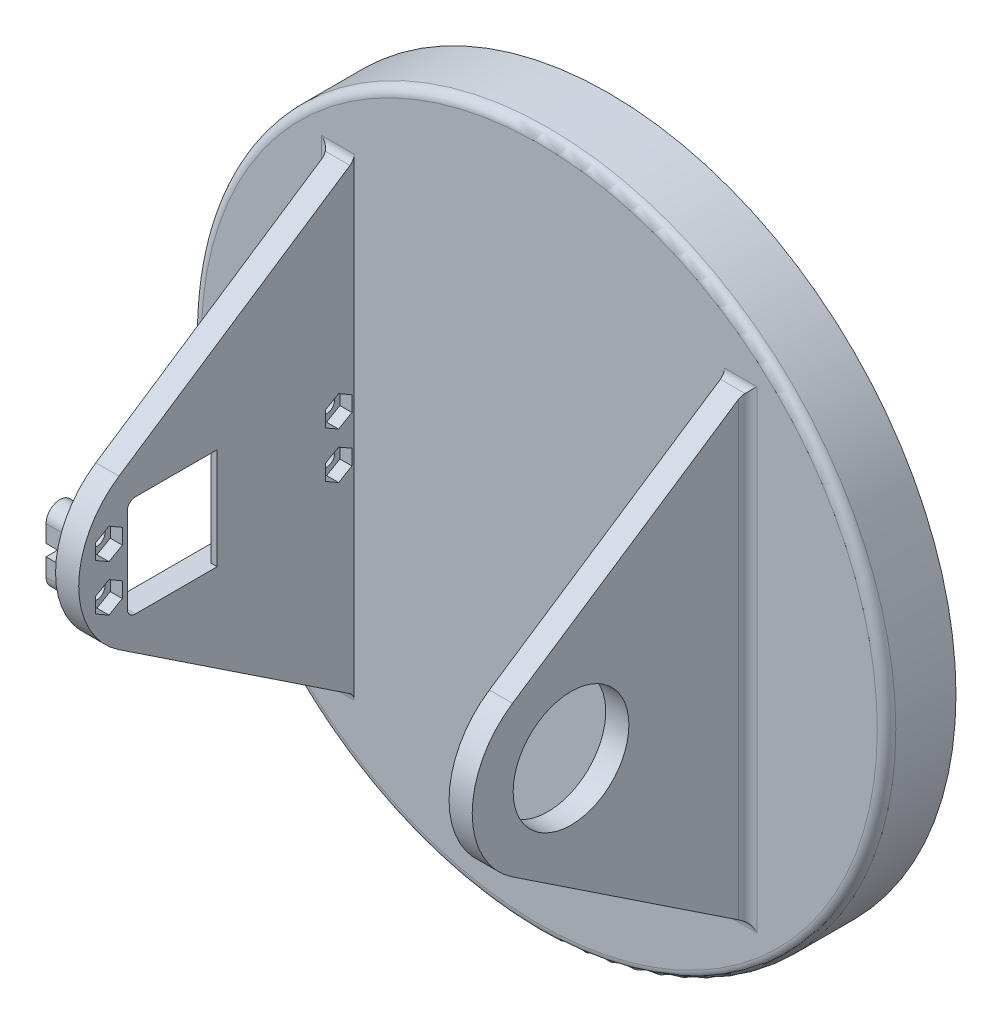
from build123d import *

# Parameters (mm, degrees)
SKETCH1_R           = 75
BASE_PLATE_DEPTH    = 15
SKETCH2_R           = 4.5
DRIVE_HOLES_DEPTH   = 10
CHAMFER1_SIZE       = 1
BASE_START          = 45
BASE_FIN_DEPTH      = 5
BASE_START_2        = 85
BASE_FIN_2_DEPTH    = 5
CUT_EXTRUDE1_REACH  = 122
CUT_EXTRUDE2_REACH  = 122
SKETCH7_R           = 1.75
BOSS_EXTRUDE1_DEPTH = 5.6
SKETCH9_R           = 1.75
CUT_EXTRUDE3_DEPTH  = 5.6
SKETCH10_W          = 4.6
SKETCH10_H          = 2.5
SKETCH10_W_2        = 6
CUT_EXTRUDE4_DEPTH  = 5.6
CUT_EXTRUDE5_DEPTH  = 2.6
BOSS_EXTRUDE2_DEPTH = 1.38
FILLET1_R           = 2
FILLET2_R           = 2
CUT_EXTRUDE6_REACH  = 37
SKETCH13_R          = 12.5


with BuildPart() as part:
    # Sketch1 → Base Plate (new body)
    with BuildSketch(Plane.XY):
        Circle(SKETCH1_R)
    extrude(amount=BASE_PLATE_DEPTH)

    # Sketch2 → Drive Holes (cut)
    with BuildSketch(Plane(origin=(0, 0, 0), x_dir=(-1, 0, 0), z_dir=(0, 0, -1))):
        with Locations((0, -25)):
            Circle(SKETCH2_R)
        with Locations((-23.776412907, -7.725424859)):
            Circle(SKETCH2_R)
        with Locations((-14.694631307, 20.225424859)):
            Circle(SKETCH2_R)
        with Locations((14.694631307, 20.225424859)):
            Circle(SKETCH2_R)
        with Locations((23.776412907, -7.725424859)):
            Circle(SKETCH2_R)
    extrude(amount=-DRIVE_HOLES_DEPTH, mode=Mode.SUBTRACT)

    # Chamfer1
    chamfer1_edges = [part.edges().sort_by_distance(p)[0] for p in [
        (28.276412907, -7.725424859, 0),
        (19.194631307, 20.225424859, 0),
        (-10.194631307, 20.225424859, 0),
        (-19.276412907, -7.725424859, 0),
        (4.5, -25, 0),
    ]]
    chamfer(chamfer1_edges, length=CHAMFER1_SIZE)

    # Sketch4 → Base Fin (add)
    with BuildSketch(Plane(origin=(0, 0, 0), x_dir=(0, 0, -1), z_dir=(1, 0, 0)).offset(BASE_START)):
        with BuildLine():
            Line((-15, 50), (-65.791986374, 16.233382914))
            ThreePointArc((-65.791986374, 16.233382914), (-74.493324261, 0), (-65.791986374, -16.233382914))
            Line((-65.791986374, -16.233382914), (-15, -50))
            Line((-15, -50), (-15, 50))
        make_face()
    extrude(amount=-BASE_FIN_DEPTH)

    # Sketch5 → Base Fin 2 (add)
    with BuildSketch(Plane.ZY.offset(-40).offset(BASE_START_2)):
        with BuildLine():
            Line((15, 50), (15, -50))
            Line((15, -50), (65.791986374, -16.233382914))
            ThreePointArc((65.791986374, -16.233382914), (74.493324261, 0), (65.791986374, 16.233382914))
            Line((65.791986374, 16.233382914), (15, 50))
        make_face()
    extrude(amount=-BASE_FIN_2_DEPTH)

    # Sketch6 → Cut-Extrude1 (cut, up to next)
    with BuildSketch(Plane.ZY.offset(45), mode=Mode.PRIVATE) as cut_extrude1_sk1:
        with BuildLine():
            Line((64, 8.832492425), (64, -9.567507575))
            ThreePointArc((64, -9.567507575), (63.487436867, -10.804944442), (62.25, -11.317507575))
            Line((62.25, -11.317507575), (24.05, -11.317507575))
            ThreePointArc((24.05, -11.317507575), (22.812563133, -10.804944442), (22.3, -9.567507575))
            Line((22.3, -9.567507575), (22.3, 8.832492425))
            ThreePointArc((22.3, 8.832492425), (22.812563133, 10.069929292), (24.05, 10.582492425))
            Line((24.05, 10.582492425), (62.25, 10.582492425))
            ThreePointArc((62.25, 10.582492425), (63.487436867, 10.069929292), (64, 8.832492425))
        make_face()
    cut_extrude1_tool1 = extrude(cut_extrude1_sk1.sketch, amount=-CUT_EXTRUDE1_REACH, mode=Mode.PRIVATE) & part.part
    add(cut_extrude1_tool1.solids().sort_by_distance((-45, -0.367508, 43.15))[0], mode=Mode.SUBTRACT)

    # Sketch7 → Cut-Extrude2 (cut, up to next)
    with BuildSketch(Plane.ZY.offset(45), mode=Mode.PRIVATE) as cut_extrude2_sk1:
        with Locations((18.35, 4.632492425)):
            Circle(SKETCH7_R)
    cut_extrude2_tool1 = extrude(cut_extrude2_sk1.sketch, amount=-CUT_EXTRUDE2_REACH, mode=Mode.PRIVATE) & part.part
    add(cut_extrude2_tool1.solids().sort_by_distance((-45, 4.632492, 18.35))[0], mode=Mode.SUBTRACT)
    # Sketch7 → Cut-Extrude2 (cut, up to next)
    with BuildSketch(Plane.ZY.offset(45), mode=Mode.PRIVATE) as cut_extrude2_sk2:
        with Locations((18.35, -5.367507575)):
            Circle(SKETCH7_R)
    cut_extrude2_tool2 = extrude(cut_extrude2_sk2.sketch, amount=-CUT_EXTRUDE2_REACH, mode=Mode.PRIVATE) & part.part
    add(cut_extrude2_tool2.solids().sort_by_distance((-45, -5.367508, 18.35))[0], mode=Mode.SUBTRACT)
    # Sketch7 → Cut-Extrude2 (cut, up to next)
    with BuildSketch(Plane.ZY.offset(45), mode=Mode.PRIVATE) as cut_extrude2_sk3:
        with Locations((67.95, -5.367507575)):
            Circle(SKETCH7_R)
    cut_extrude2_tool3 = extrude(cut_extrude2_sk3.sketch, amount=-CUT_EXTRUDE2_REACH, mode=Mode.PRIVATE) & part.part
    add(cut_extrude2_tool3.solids().sort_by_distance((-45, -5.367508, 67.95))[0], mode=Mode.SUBTRACT)
    # Sketch7 → Cut-Extrude2 (cut, up to next)
    with BuildSketch(Plane.ZY.offset(45), mode=Mode.PRIVATE) as cut_extrude2_sk4:
        with Locations((67.95, 4.632492425)):
            Circle(SKETCH7_R)
    cut_extrude2_tool4 = extrude(cut_extrude2_sk4.sketch, amount=-CUT_EXTRUDE2_REACH, mode=Mode.PRIVATE) & part.part
    add(cut_extrude2_tool4.solids().sort_by_distance((-45, 4.632492, 67.95))[0], mode=Mode.SUBTRACT)

    # Sketch8 → Boss-Extrude1 (add)
    with BuildSketch(Plane.ZY.offset(45)):
        with BuildLine():
            Line((70.95, 4.632492425), (70.95, -5.367507575))
            ThreePointArc((70.95, -5.367507575), (67.95, -8.367507575), (64.95, -5.367507575))
            Line((64.95, -5.367507575), (64.95, 4.632492425))
            ThreePointArc((64.95, 4.632492425), (67.95, 7.632492425), (70.95, 4.632492425))
        make_face()
        with BuildLine():
            Line((15, 7.632492425), (15, 0))
            Line((15, 0), (15, -8.367507575))
            Line((15, -8.367507575), (18.35, -8.367507575))
            ThreePointArc((18.35, -8.367507575), (20.471320344, -7.488827919), (21.35, -5.367507575))
            Line((21.35, -5.367507575), (21.35, 4.632492425))
            ThreePointArc((21.35, 4.632492425), (20.471320344, 6.753812769), (18.35, 7.632492425))
            Line((18.35, 7.632492425), (15, 7.632492425))
        make_face()
    extrude(amount=BOSS_EXTRUDE1_DEPTH)

    # Sketch9 → Cut-Extrude3 (cut)
    with BuildSketch(Plane(origin=(-45, 0, 0), x_dir=(0, 0, -1), z_dir=(1, 0, 0))):
        with Locations((-67.95, -5.367507575)):
            Circle(SKETCH9_R)
        with Locations((-67.95, 4.632492425)):
            Circle(SKETCH9_R)
        with Locations((-18.35, -5.367507575)):
            Circle(SKETCH9_R)
        with Locations((-18.35, 4.632492425)):
            Circle(SKETCH9_R)
    extrude(amount=-CUT_EXTRUDE3_DEPTH, mode=Mode.SUBTRACT)

    # Sketch10 → Cut-Extrude4 (cut)
    with BuildSketch(Plane.ZY.offset(50.6)):
        with Locations((19.05, -0.367507575)):
            Rectangle(SKETCH10_W, SKETCH10_H)
        with Locations((67.95, -0.324654002)):
            Rectangle(SKETCH10_W_2, SKETCH10_H)
    extrude(amount=-CUT_EXTRUDE4_DEPTH, mode=Mode.SUBTRACT)

    # Sketch11 → Cut-Extrude5 (cut)
    with BuildSketch(Plane(origin=(-40, 0, 0), x_dir=(0, 0, -1), z_dir=(1, 0, 0))):
        Polygon((-65.075, -7.027389599), (-65.075, -3.707625551), (-67.95, -2.047743527), (-70.825, -3.707625551), (-70.825, -7.027389599), (-67.95, -8.687271623), align=None)
        Polygon((-65.075, 2.972610401), (-65.075, 6.292374449), (-67.95, 7.952256473), (-70.825, 6.292374449), (-70.825, 2.972610401), (-67.95, 1.312728377), align=None)
        Polygon((-15.475, -7.027389599), (-15.475, -3.707625551), (-18.35, -2.047743527), (-21.225, -3.707625551), (-21.225, -7.027389599), (-18.35, -8.687271623), align=None)
        Polygon((-15.475, 2.972610401), (-15.475, 6.292374449), (-18.35, 7.952256473), (-21.225, 6.292374449), (-21.225, 2.972610401), (-18.35, 1.312728377), align=None)
    extrude(amount=-CUT_EXTRUDE5_DEPTH, mode=Mode.SUBTRACT)

    # Sketch12 → Boss-Extrude2 (add)
    with BuildSketch(Plane(origin=(-40, 0, 0), x_dir=(0, 0, -1), z_dir=(1, 0, 0))):
        with BuildLine():
            Line((-44.572101834, -11.317507575), (-44.572101834, 10.582492425))
            Line((-44.572101834, 10.582492425), (-24.05, 10.582492425))
            ThreePointArc((-24.05, 10.582492425), (-22.812563133, 10.069929292), (-22.3, 8.832492425))
            Line((-22.3, 8.832492425), (-22.3, -9.567507575))
            ThreePointArc((-22.3, -9.567507575), (-22.812563133, -10.804944442), (-24.05, -11.317507575))
            Line((-24.05, -11.317507575), (-44.572101834, -11.317507575))
        make_face()
    extrude(amount=-BOSS_EXTRUDE2_DEPTH)

    # Fillet1
    fillet1_edges = [part.edges().sort_by_distance(p)[0] for p in [
        (-45, -29.183753787, 15),
        (-47.8, -8.367507575, 15),
        (-47.8, 7.632492425, 15),
        (42.5, 50, 15),
        (42.5, -50, 15),
        (45, 0, 15),
        (-42.5, 50, 15),
        (-42.5, -50, 15),
        (-45, 28.816246213, 15),
    ]]
    fillet(fillet1_edges, radius=FILLET1_R)

    # Fillet2
    fillet2_edges = [part.edges().sort_by_distance(p)[0] for p in [
        (-75, 0, 15),
    ]]
    fillet(fillet2_edges, radius=FILLET2_R)

    # Sketch13 → Cut-Extrude6 (cut, up to next)
    with BuildSketch(Plane.ZY.offset(-40), mode=Mode.PRIVATE) as cut_extrude6_sk1:
        with Locations((53.15, -0.367507575)):
            Circle(SKETCH13_R)
    cut_extrude6_tool1 = extrude(cut_extrude6_sk1.sketch, amount=-CUT_EXTRUDE6_REACH, mode=Mode.PRIVATE) & part.part
    add(cut_extrude6_tool1.solids().sort_by_distance((40, -0.367508, 53.15))[0], mode=Mode.SUBTRACT)


solid = part.part
